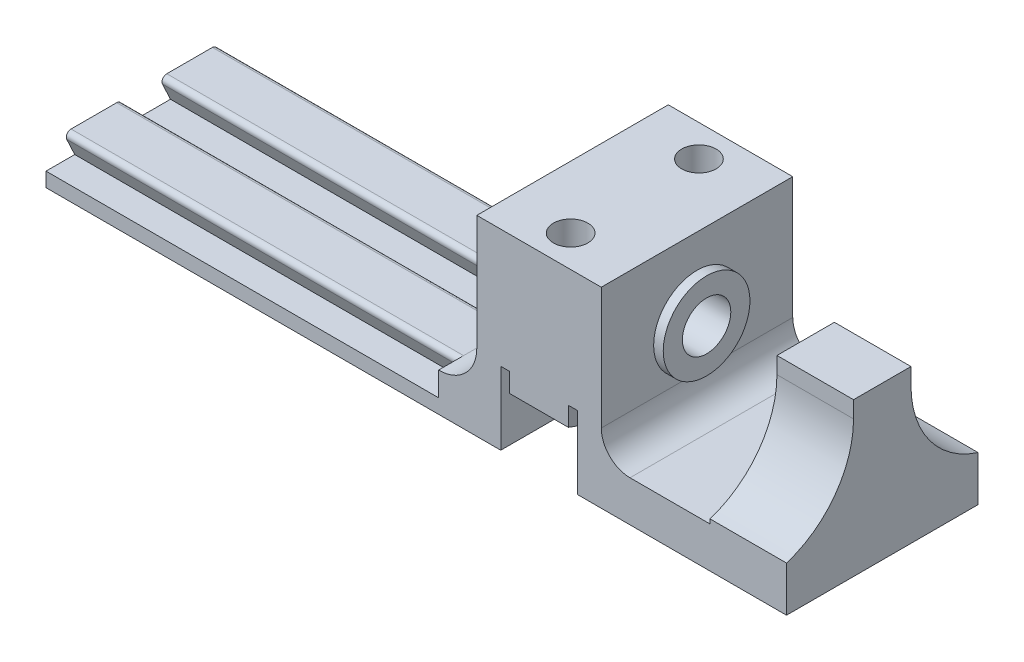
from build123d import *

# Parameters (mm, degrees)
SKETCH1_W            = 58
SKETCH1_H            = 80
BOSS_EXTRUDE1_DEPTH  = 4
CUT_EXTRUDE1_DEPTH   = 25
SKETCH5_W            = 13
SKETCH5_H            = 16
BOSS_EXTRUDE3_DEPTH  = 80
SKETCH6_R            = 2.53
CUT_EXTRUDE2_DEPTH   = 59
SKETCH7_R            = 4.53
SKETCH7_R_2          = 2.53
BOSS_EXTRUDE4_DEPTH  = 1
SKETCH8_R            = 1.8
CUT_EXTRUDE3_DEPTH   = 21
SKETCH9_W            = 8
SKETCH9_H            = 80
CUT_EXTRUDE4_DEPTH   = 7.6
SKETCH13_W           = 6
SKETCH13_H           = 4.261
BOSS_EXTRUDE6_DEPTH  = 11.35
SKETCH14_W           = 6
SKETCH14_H           = 16
BOSS_EXTRUDE7_DEPTH  = 8
SKETCH15_W           = 40
SKETCH15_H           = 4.261
BOSS_EXTRUDE8_DEPTH  = 19.35
FILLET1_R            = 10
FILLET2_R            = 3
FILLET3_R            = 3
SKETCH17_W           = 17
SKETCH17_H           = 24
CUT_EXTRUDE6_DEPTH   = 5
FILLET4_R            = 14
FILLET5_R            = 4
FILLET6_R            = 2
FILLET7_R            = 0.5
BOSS_EXTRUDE10_DEPTH = 2
SKETCH19_W           = 58
SKETCH19_H           = 5.571501033
SKETCH19_H_2         = 14.101029475
CUT_EXTRUDE7_DEPTH   = 21
SKETCH20_W           = 96.7
SKETCH20_H           = 30
CUT_EXTRUDE8_DEPTH   = 21.0000001
CUT_EXTRUDE9_DEPTH   = 16


with BuildPart() as part:
    # Sketch1 → Boss-Extrude1 (new body)
    with BuildSketch(Plane(origin=(0, 0, 0), x_dir=(1, 0, 0), z_dir=(0, 1, 0))):
        Rectangle(SKETCH1_W, SKETCH1_H)
    extrude(amount=BOSS_EXTRUDE1_DEPTH)

    # Sketch2 → Cut-Extrude1 (cut)
    with BuildSketch(Plane.ZY.offset(29)):
        Polygon((1.834230855, 4), (-1.834230855, 4), (-3, 1.5), (3, 1.5), align=None)
        Polygon((8.165769145, 4), (11.834230855, 4), (13, 1.5), (7, 1.5), align=None)
        Polygon((-7, 1.5), (-8.165769145, 4), (-11.834230855, 4), (-13, 1.5), align=None)
    extrude(amount=-CUT_EXTRUDE1_DEPTH, mode=Mode.SUBTRACT)

    # Sketch5 → Boss-Extrude3 (add)
    with BuildSketch(Plane.XY.offset(40)):
        with Locations((22.5, 12)):
            Rectangle(SKETCH5_W, SKETCH5_H)
    extrude(amount=-BOSS_EXTRUDE3_DEPTH)

    # Sketch6 → Cut-Extrude2 (cut, through all)
    with BuildSketch(Plane(origin=(29, 0, 0), x_dir=(0, 0, -1), z_dir=(1, 0, 0))):
        with Locations((0, 12)):
            Circle(SKETCH6_R)
    extrude(amount=-CUT_EXTRUDE2_DEPTH, mode=Mode.SUBTRACT)

    # Sketch7 → Boss-Extrude4 (add)
    with BuildSketch(Plane(origin=(29, 0, 0), x_dir=(0, 0, -1), z_dir=(1, 0, 0))):
        with Locations((0, 12)):
            Circle(SKETCH7_R)
        with Locations((0, 12)):
            Circle(SKETCH7_R_2, mode=Mode.SUBTRACT)
    extrude(amount=BOSS_EXTRUDE4_DEPTH)

    # Sketch8 → Cut-Extrude3 (cut, through all)
    with BuildSketch(Plane(origin=(0, 20, 0), x_dir=(1, 0, 0), z_dir=(0, 1, 0))):
        with Locations((22.5, 6.7)):
            Circle(SKETCH8_R)
        with Locations((22.5, -6.7)):
            Circle(SKETCH8_R)
    extrude(amount=-CUT_EXTRUDE3_DEPTH, mode=Mode.SUBTRACT)

    # Sketch9 → Cut-Extrude4 (cut)
    with BuildSketch(Plane.XZ):
        with Locations((22.5, 0)):
            Rectangle(SKETCH9_W, SKETCH9_H)
    extrude(amount=-CUT_EXTRUDE4_DEPTH, mode=Mode.SUBTRACT)

    # Sketch13 → Boss-Extrude6 (add)
    with BuildSketch(Plane(origin=(29, 0, 0), x_dir=(0, 0, -1), z_dir=(1, 0, 0))):
        with Locations((0, 2.1305)):
            Rectangle(SKETCH13_W, SKETCH13_H)
    extrude(amount=BOSS_EXTRUDE6_DEPTH)

    # Sketch14 → Boss-Extrude7 (add)
    with BuildSketch(Plane(origin=(40.35, 0, 0), x_dir=(0, 0, -1), z_dir=(1, 0, 0))):
        with Locations((0, 8)):
            Rectangle(SKETCH14_W, SKETCH14_H)
    extrude(amount=BOSS_EXTRUDE7_DEPTH)

    # Sketch15 → Boss-Extrude8 (add)
    with BuildSketch(Plane(origin=(29, 0, 0), x_dir=(0, 0, -1), z_dir=(1, 0, 0))):
        with Locations((0, 2.1305)):
            Rectangle(SKETCH15_W, SKETCH15_H)
    extrude(amount=BOSS_EXTRUDE8_DEPTH)

    # Fillet1
    fillet1_edges = [part.edges().sort_by_distance(p)[0] for p in [
        (44.35, 4.261, 3),
        (44.35, 4.261, -3),
    ]]
    fillet(fillet1_edges, radius=FILLET1_R)

    # Fillet2
    fillet2_edges = [part.edges().sort_by_distance(p)[0] for p in [
        (29, 4.261, 0),
    ]]
    fillet(fillet2_edges, radius=FILLET2_R)

    # Fillet3
    fillet3_edges = [part.edges().sort_by_distance(p)[0] for p in [
        (29, 2.1305, -20),
        (29, 2.1305, 20),
    ]]
    fillet(fillet3_edges, radius=FILLET3_R)

    # Sketch17 → Cut-Extrude6 (cut, through all)
    with BuildSketch(Plane(origin=(0, 4, 0), x_dir=(1, 0, 0), z_dir=(0, 1, 0))):
        with Locations((7.5, -24)):
            Rectangle(SKETCH17_W, SKETCH17_H)
        with Locations((7.5, 24)):
            Rectangle(SKETCH17_W, SKETCH17_H)
    extrude(amount=-CUT_EXTRUDE6_DEPTH, mode=Mode.SUBTRACT)

    # Fillet4
    fillet4_edges = [part.edges().sort_by_distance(p)[0] for p in [
        (16, 4, 38),
        (16, 4, -38),
    ]]
    fillet(fillet4_edges, radius=FILLET4_R)

    # Fillet5
    fillet5_edges = [part.edges().sort_by_distance(p)[0] for p in [
        (16, 4, 0),
    ]]
    fillet(fillet5_edges, radius=FILLET5_R)

    # Fillet6
    fillet6_edges = [part.edges().sort_by_distance(p)[0] for p in [
        (16, 6, 12),
        (16, 11, 36),
        (16, 11, -36),
        (16, 6, -12),
    ]]
    fillet(fillet6_edges, radius=FILLET6_R)

    # Fillet7
    fillet7_edges = [part.edges().sort_by_distance(p)[0] for p in [
        (-16.5, 4, -11.834230855),
        (-16.5, 4, -8.165769145),
        (-16.5, 4, 8.165769145),
        (-16.5, 4, 11.834230855),
        (-16.5, 4, 1.834230855),
        (-16.5, 4, -1.834230855),
    ]]
    fillet(fillet7_edges, radius=FILLET7_R)

    # Sketch18 → Boss-Extrude10 (add)
    with BuildSketch(Plane.XZ.offset(-7.6)):
        Polygon((20.016762412, 40.30109367), (24.983237588, 40.30109367), (27.466475177, 36), (24.983237588, 31.69890633), (20.016762412, 31.69890633), (17.533524823, 36), align=None)
        Polygon((20.882787815, 38.80109367), (24.117212185, 38.80109367), (25.734424369, 36), (24.117212185, 33.19890633), (20.882787815, 33.19890633), (19.265575631, 36), align=None, mode=Mode.SUBTRACT)
        Polygon((20.016762412, 11.00109367), (24.983237588, 11.00109367), (27.466475177, 6.7), (24.983237588, 2.39890633), (20.016762412, 2.39890633), (17.533524823, 6.7), align=None)
        Polygon((20.882787815, 9.50109367), (24.117212185, 9.50109367), (25.734424369, 6.7), (24.117212185, 3.89890633), (20.882787815, 3.89890633), (19.265575631, 6.7), align=None, mode=Mode.SUBTRACT)
        Polygon((20.016762412, -2.39890633), (24.983237588, -2.39890633), (27.466475177, -6.7), (24.983237588, -11.00109367), (20.016762412, -11.00109367), (17.533524823, -6.7), align=None)
        Polygon((20.882787815, -3.89890633), (24.117212185, -3.89890633), (25.734424369, -6.7), (24.117212185, -9.50109367), (20.882787815, -9.50109367), (19.265575631, -6.7), align=None, mode=Mode.SUBTRACT)
        Polygon((20.016762412, -31.69890633), (24.983237588, -31.69890633), (27.466475177, -36), (24.983237588, -40.30109367), (20.016762412, -40.30109367), (17.533524823, -36), align=None)
        Polygon((20.882787815, -33.19890633), (24.117212185, -33.19890633), (25.734424369, -36), (24.117212185, -38.80109367), (20.882787815, -38.80109367), (19.265575631, -36), align=None, mode=Mode.SUBTRACT)
    extrude(amount=BOSS_EXTRUDE10_DEPTH)

    # Sketch19 → Cut-Extrude7 (cut, through all)
    with BuildSketch(Plane.XZ):
        with Locations((0, -42.785750517)):
            Rectangle(SKETCH19_W, SKETCH19_H)
        with Locations((0, 47.050514738)):
            Rectangle(SKETCH19_W, SKETCH19_H_2)
    extrude(amount=-CUT_EXTRUDE7_DEPTH, mode=Mode.SUBTRACT)

    # Sketch20 → Cut-Extrude8 (cut, through all)
    with BuildSketch(Plane(origin=(0, 20, 0), x_dir=(1, 0, 0), z_dir=(0, 1, 0))):
        with Locations((0, 25)):
            Rectangle(SKETCH20_W, SKETCH20_H)
        with Locations((0, -25)):
            Rectangle(SKETCH20_W, SKETCH20_H)
    extrude(amount=-CUT_EXTRUDE8_DEPTH, mode=Mode.SUBTRACT)

    # Sketch22 → Cut-Extrude9 (cut)
    with BuildSketch(Plane.ZY.offset(4)):
        with BuildLine():
            Line((-10, 4), (-10, 1.5))
            Line((-10, 1.5), (-7, 1.5))
            Line((-7, 1.5), (-7.83408025, 3.288690869))
            ThreePointArc((-7.83408025, 3.288690869), (-7.80262208, 3.768649804), (-7.380926357, 4))
            Line((-7.380926357, 4), (-10, 4))
        make_face()
        with BuildLine():
            Line((3, 1.5), (2.16591975, 3.288690869))
            ThreePointArc((2.16591975, 3.288690869), (2.19737792, 3.768649804), (2.619073643, 4))
            Line((2.619073643, 4), (-2.619073643, 4))
            ThreePointArc((-2.619073643, 4), (-2.19737792, 3.768649804), (-2.16591975, 3.288690869))
            Line((-2.16591975, 3.288690869), (-3, 1.5))
            Line((-3, 1.5), (3, 1.5))
        make_face()
        with BuildLine():
            Line((7, 1.5), (10, 1.5))
            Line((10, 1.5), (10, 4))
            Line((10, 4), (7.380926357, 4))
            ThreePointArc((7.380926357, 4), (7.80262208, 3.768649804), (7.83408025, 3.288690869))
            Line((7.83408025, 3.288690869), (7, 1.5))
        make_face()
    extrude(amount=-CUT_EXTRUDE9_DEPTH, mode=Mode.SUBTRACT)


solid = part.part
